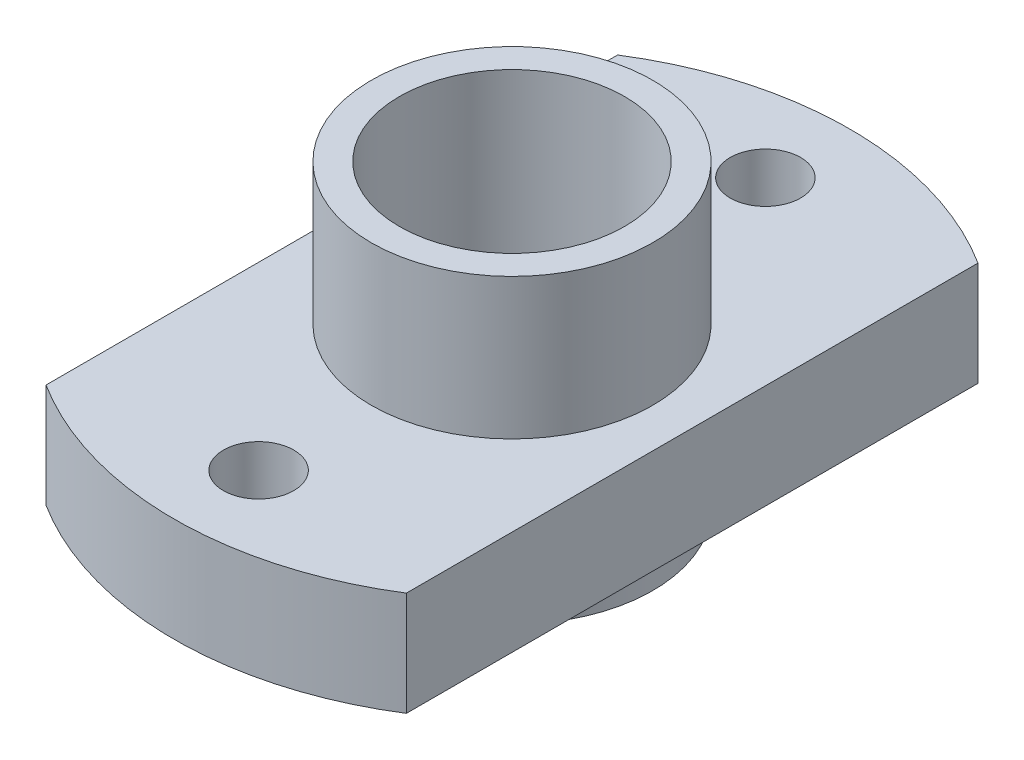
from build123d import *

# Parameters (mm, degrees)
BOSS_EXTRUDE1_DEPTH      = 3.7
SKETCH2_R                = 5
BOSS_EXTRUDE2_DEPTH      = 5
BOSS_EXTRUDE2_DEPTH_BACK = 5.7
HOLE_WIZARD_M3_1_D       = 2.5
HOLE_WIZARD_M3_1_DEPTH   = 3.7
CUT_EXTRUDE_1_REACH      = 12.7
SKETCH_3_R               = 4


with BuildPart() as part:
    # Sketch1 → Boss-Extrude1 (new body)
    with BuildSketch(Plane(origin=(0, 0, 0), x_dir=(1, 0, 0), z_dir=(0, 1, 0))):
        with BuildLine():
            Line((-6.4, 10.150862032), (-6.4, -10.150862032))
            ThreePointArc((-6.4, -10.150862032), (0, -12), (6.4, -10.150862032))
            Line((6.4, -10.150862032), (6.4, 10.150862032))
            ThreePointArc((6.4, 10.150862032), (0, 12), (-6.4, 10.150862032))
        make_face()
    extrude(amount=BOSS_EXTRUDE1_DEPTH)

    # Sketch2 → Boss-Extrude2 (add, two sides)
    with BuildSketch(Plane(origin=(0, 3.7, 0), x_dir=(1, 0, 0), z_dir=(0, 1, 0))) as boss_extrude2_sk:
        Circle(SKETCH2_R)
    extrude(amount=BOSS_EXTRUDE2_DEPTH)
    extrude(boss_extrude2_sk.sketch, amount=-BOSS_EXTRUDE2_DEPTH_BACK)

    # M3 螺纹孔1
    with Locations(Plane(origin=(0, 0, 0), x_dir=(-1, 0, 0), z_dir=(0, -1, 0))):
        with Locations((0, -9), (0, 9)):
            Hole(HOLE_WIZARD_M3_1_D / 2, depth=HOLE_WIZARD_M3_1_DEPTH)

    # 草图3 → 切除-拉伸1 (cut, up to next)
    with BuildSketch(Plane.XZ.offset(2), mode=Mode.PRIVATE) as cut_extrude_1_sk1:
        Circle(SKETCH_3_R)
    cut_extrude_1_tool1 = extrude(cut_extrude_1_sk1.sketch, amount=-CUT_EXTRUDE_1_REACH, mode=Mode.PRIVATE) & part.part
    add(cut_extrude_1_tool1.solids().sort_by_distance((0, -2, 0))[0], mode=Mode.SUBTRACT)


solid = part.part
